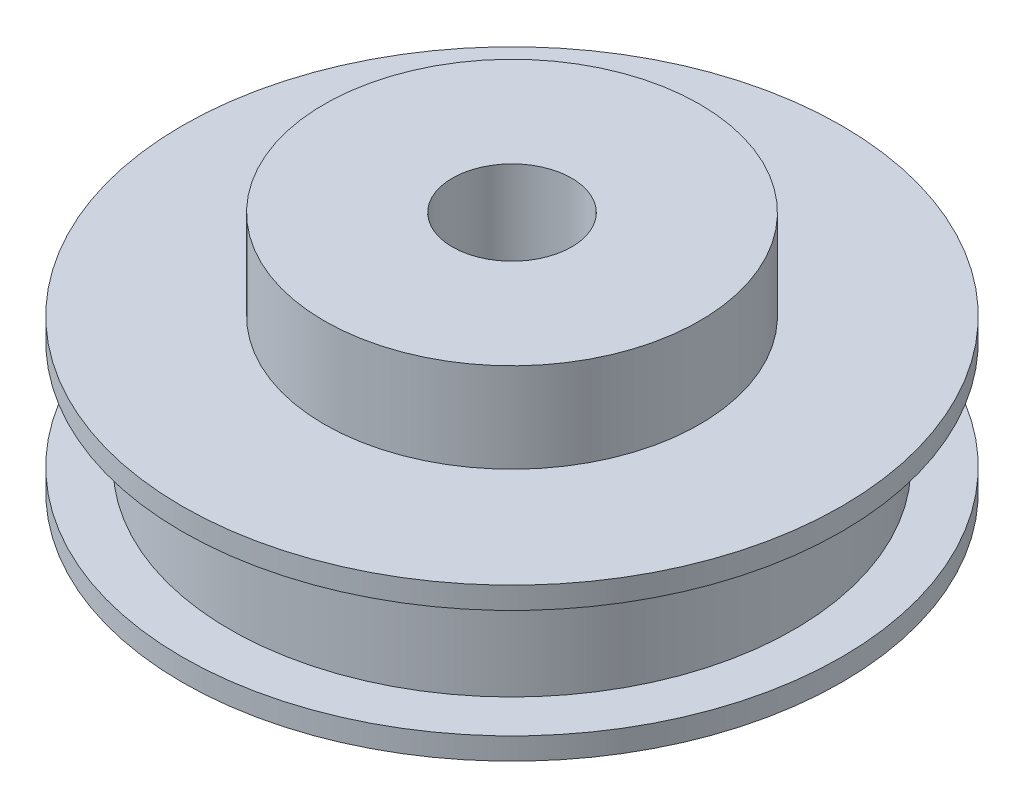
from build123d import *

# Parameters (mm, degrees)
SKETCH1_R           = 21.971
BOSS_EXTRUDE1_DEPTH = 10.16
SKETCH2_W           = 3.175
SKETCH2_H           = 7.239
SKETCH3_R           = 12.5095
BOSS_EXTRUDE2_DEPTH = 5.969
SKETCH4_R           = 3.9751
CUT_EXTRUDE1_DEPTH  = 17.129


with BuildPart() as part:
    # Sketch1 → Boss-Extrude1 (new body)
    with BuildSketch(Plane(origin=(0, 0, 0), x_dir=(1, 0, 0), z_dir=(0, 1, 0))):
        Circle(SKETCH1_R)
    extrude(amount=BOSS_EXTRUDE1_DEPTH)

    # Sketch2 → Cut-Revolve1 (revolve, cut)
    with BuildSketch(Plane.XY):
        with Locations((-20.3835, 5.08)):
            Rectangle(SKETCH2_W, SKETCH2_H)
    revolve(axis=Axis((0, 0, 0), (0, 1, 0)), mode=Mode.SUBTRACT)

    # Sketch3 → Boss-Extrude2 (add)
    with BuildSketch(Plane(origin=(0, 10.16, 0), x_dir=(1, 0, 0), z_dir=(0, 1, 0))):
        Circle(SKETCH3_R)
    extrude(amount=BOSS_EXTRUDE2_DEPTH)

    # Sketch4 → Cut-Extrude1 (cut, through all)
    with BuildSketch(Plane(origin=(0, 16.129, 0), x_dir=(1, 0, 0), z_dir=(0, 1, 0))):
        Circle(SKETCH4_R)
    extrude(amount=-CUT_EXTRUDE1_DEPTH, mode=Mode.SUBTRACT)


solid = part.part
